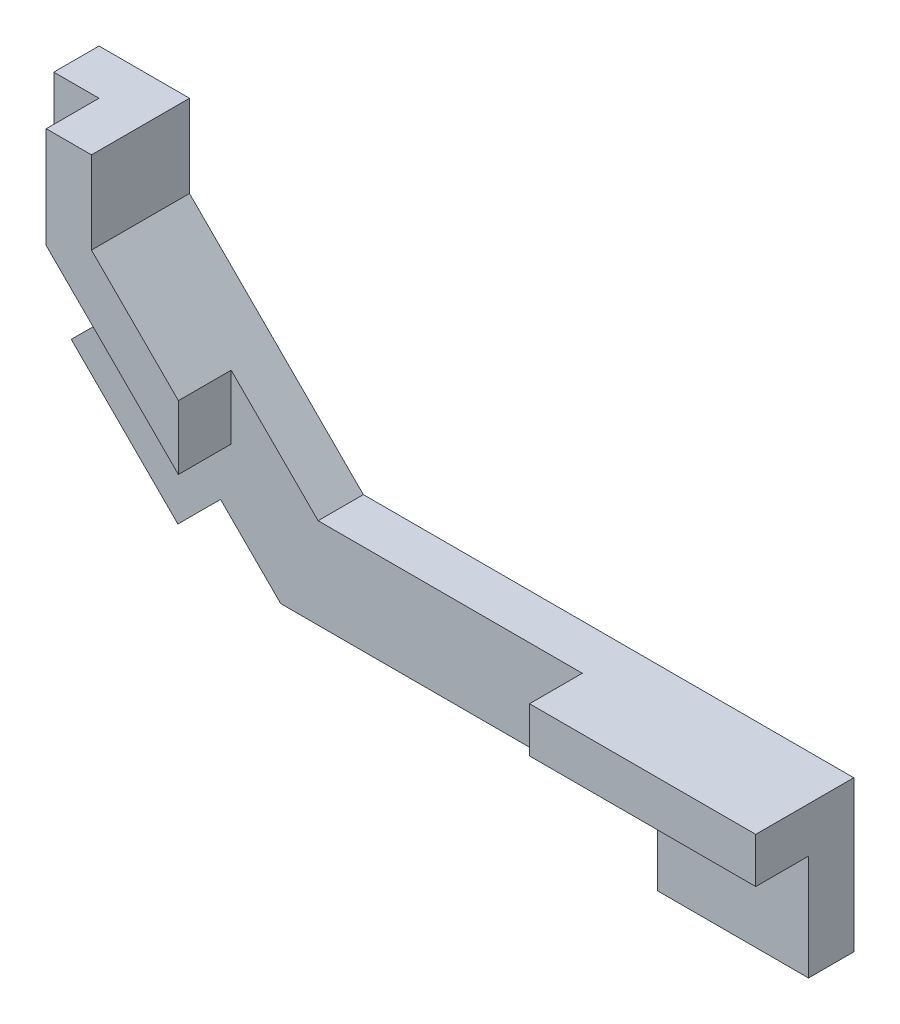
from build123d import *

# Parameters (mm, degrees)
SKETCH1_W                = 35
SKETCH1_H                = 3
BOSS_EXTRUDE1_DEPTH      = 6
BOSS_EXTRUDE2_DEPTH      = 3
SKETCH3_W                = 15
SKETCH3_H                = 3
BOSS_EXTRUDE3_DEPTH      = 3.5
BOSS_EXTRUDE3_DEPTH_BACK = 3
SKETCH4_W                = 10
SKETCH4_H                = 3
BOSS_EXTRUDE4_DEPTH      = 4
SKETCH5_W                = 3
SKETCH5_H                = 10
BOSS_EXTRUDE5_DEPTH      = 4


with BuildPart() as part:
    # Sketch1 → Boss-Extrude1 (new body)
    with BuildSketch(Plane(origin=(0, 0, 0), x_dir=(1, 0, 0), z_dir=(0, 1, 0))):
        Rectangle(SKETCH1_W, SKETCH1_H)
    extrude(amount=BOSS_EXTRUDE1_DEPTH)

    # Sketch2 → Boss-Extrude2 (add)
    with BuildSketch(Plane.XY.offset(1.5)):
        Polygon((-17.5, 0), (-32.547232304, 15.047232304), (-32.547232304, 22.997232304), (-26.547232304, 22.997232304), (-26.547232304, 17.527232304), (-15.02, 6), (-17.5, 6), align=None)
    extrude(amount=-BOSS_EXTRUDE2_DEPTH)

    # Sketch3 → Boss-Extrude3 (add, two sides)
    with BuildSketch(Plane.XY.offset(1.5)) as boss_extrude3_sk:
        Polygon((-26.547232304, 22.997232304), (-29.547232304, 22.997232304), (-29.547232304, 16.284591617), (-20.783616152, 7.520975465), (-20.783616152, 11.763616152), (-26.547232304, 17.527232304), align=None)
        with Locations((10, 4.5)):
            Rectangle(SKETCH3_W, SKETCH3_H)
    extrude(amount=BOSS_EXTRUDE3_DEPTH)
    extrude(boss_extrude3_sk.sketch, amount=-BOSS_EXTRUDE3_DEPTH_BACK)

    # Sketch4 → Boss-Extrude4 (add)
    with BuildSketch(Plane.XZ):
        with Locations((12.5, 0)):
            Rectangle(SKETCH4_W, SKETCH4_H)
    extrude(amount=BOSS_EXTRUDE4_DEPTH)

    # Sketch5 → Boss-Extrude5 (add)
    with BuildSketch(Plane(origin=(-8.75, -8.75, 0), x_dir=(0, 0, 1), z_dir=(-0.707106781, -0.707106781, 0))):
        with Locations((0, 23.014368671)):
            Rectangle(SKETCH5_W, SKETCH5_H)
    extrude(amount=BOSS_EXTRUDE5_DEPTH)


solid = part.part
